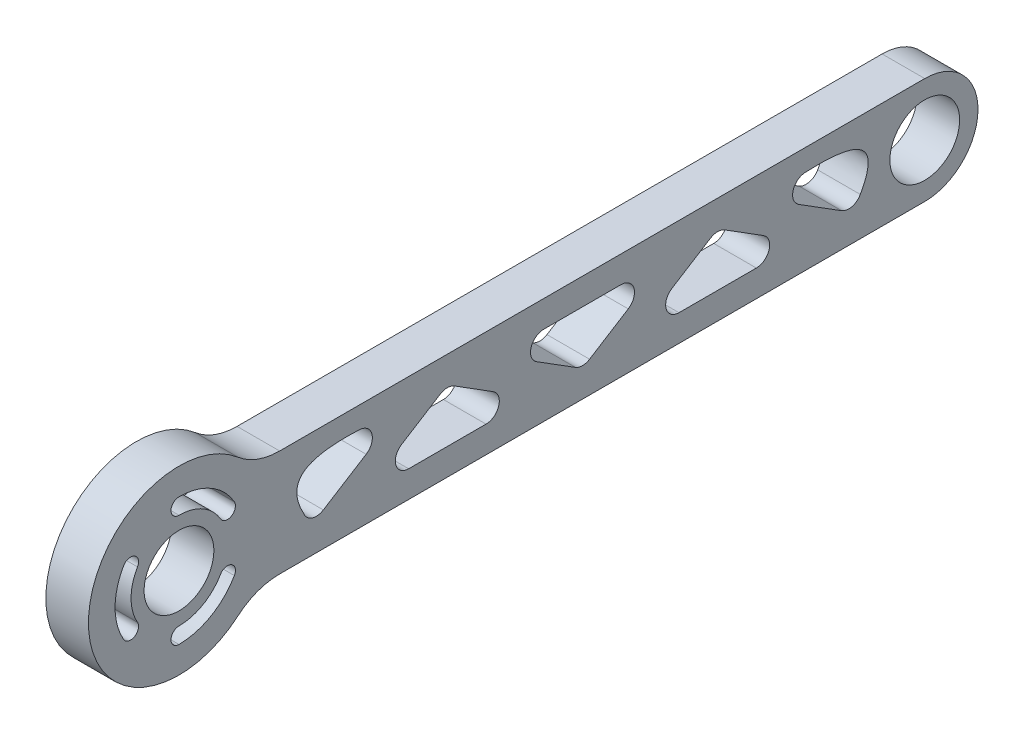
from build123d import *

# Parameters (mm, degrees)
SKETCH_1_R      = 6.55
EXTRUDE_1_DEPTH = 8


with BuildPart() as part:
    # 草图1 → 凸台-拉伸1 (new body)
    with BuildSketch(Plane(origin=(-4, 0, 0), x_dir=(0, -1, 0), z_dir=(-1, 0, 0))):
        with BuildLine():
            Line((-10, -18.894443628), (-10, -140))
            ThreePointArc((-10, -140), (0, -150), (10, -140))
            Line((10, -140), (10, -18.894443628))
            ThreePointArc((10, -18.894443628), (10.74741409, -14.725593625), (12.896551724, -11.076053161))
            ThreePointArc((12.896551724, -11.076053161), (0, 17), (-12.896551724, -11.076053161))
            ThreePointArc((-12.896551724, -11.076053161), (-10.74741409, -14.725593625), (-10, -18.894443628))
        make_face()
        with Locations((0, -140)):
            Circle(SKETCH_1_R, mode=Mode.SUBTRACT)
        Circle(SKETCH_1_R, mode=Mode.SUBTRACT)
        with BuildLine():
            Line((-4.168179012, -99.797532142), (0.381550311, -92.536811957))
            ThreePointArc((0.381550311, -92.536811957), (3.190606899, -91.461560083), (5, -93.864279815))
            Line((5, -93.864279815), (5, -108.385720185))
            ThreePointArc((5, -108.385720185), (3.190606899, -110.788439917), (0.381550311, -109.713188043))
            Line((0.381550311, -109.713188043), (-4.168179012, -102.452467858))
            ThreePointArc((-4.168179012, -102.452467858), (-4.549729323, -101.125), (-4.168179012, -99.797532142))
        make_face(mode=Mode.SUBTRACT)
        with BuildLine():
            Line((-1.347932676, -116.369603301), (3.683273316, -124.398691695))
            ThreePointArc((3.683273316, -124.398691695), (3.98786354, -126.341689874), (2.792876182, -127.903746961))
            add(Edge.make_bspline(
                [(2.792876182, -127.903746961), (-2.877603269, -131.101619406), (-5.985402229, -127.808170374), (-6.076762251, -119.793304589), (-5.963124704, -117.569487096)],
                knots=[0.005408839, 0.005408839, 0.005408839, 0.005408839, 0.693539789, 0.980498212, 0.980498212, 0.980498212, 0.980498212], degree=3))
            ThreePointArc((-5.963124704, -117.569487096), (-4.09543452, -115.277506448), (-1.347932676, -116.369603301))
        make_face(mode=Mode.SUBTRACT)
        with BuildLine():
            Line((0.381550311, -58.963188043), (-4.168179012, -51.702467858))
            ThreePointArc((-4.168179012, -51.702467858), (-4.549729323, -50.375), (-4.168179012, -49.047532142))
            Line((-4.168179012, -49.047532142), (0.381550311, -41.786811957))
            ThreePointArc((0.381550311, -41.786811957), (3.190606899, -40.711560083), (5, -43.114279815))
            Line((5, -43.114279815), (5, -57.635720185))
            ThreePointArc((5, -57.635720185), (3.190606899, -60.038439917), (0.381550311, -58.963188043))
        make_face(mode=Mode.SUBTRACT)
        with BuildLine():
            Line((3.683273317, -27.101308304), (-1.347932676, -35.130396699))
            ThreePointArc((-1.347932676, -35.130396699), (-4.095434519, -36.222493552), (-5.963124704, -33.930512906))
            add(Edge.make_bspline(
                [(-5.963124704, -33.930512906), (-6.076762251, -31.706695412), (-5.98540223, -23.691829624), (-2.877603269, -20.398380591), (2.792876182, -23.596253037)],
                knots=[0.005408839, 0.005408839, 0.005408839, 0.005408839, 0.292367263, 0.980498213, 0.980498213, 0.980498213, 0.980498213], degree=3))
            ThreePointArc((2.792876182, -23.596253037), (3.987863541, -25.158310124), (3.683273317, -27.101308304))
        make_face(mode=Mode.SUBTRACT)
        with BuildLine():
            Line((4.168179012, -77.077467858), (-0.381550311, -84.338188043))
            ThreePointArc((-0.381550311, -84.338188043), (-3.190606899, -85.413439917), (-5, -83.010720185))
            Line((-5, -83.010720185), (-5, -68.489279815))
            ThreePointArc((-5, -68.489279815), (-3.190606899, -66.086560083), (-0.381550311, -67.161811957))
            Line((-0.381550311, -67.161811957), (4.168179012, -74.422532142))
            ThreePointArc((4.168179012, -74.422532142), (4.549729323, -75.75), (4.168179012, -77.077467858))
        make_face(mode=Mode.SUBTRACT)
        with BuildLine():
            ThreePointArc((-4.5, 7.794228634), (-6.549038106, 8.34326674), (-6, 10.392304845))
            ThreePointArc((-6, 10.392304845), (0, 12), (6, 10.392304845))
            ThreePointArc((6, 10.392304845), (6.549038106, 8.34326674), (4.5, 7.794228634))
            ThreePointArc((4.5, 7.794228634), (0, 9), (-4.5, 7.794228634))
        make_face(mode=Mode.SUBTRACT)
        with BuildLine():
            ThreePointArc((9, 0), (10.5, 1.5), (12, 0))
            ThreePointArc((12, 0), (10.392304845, -6), (6, -10.392304845))
            ThreePointArc((6, -10.392304845), (3.950961894, -9.84326674), (4.5, -7.794228634))
            ThreePointArc((4.5, -7.794228634), (7.794228634, -4.5), (9, 0))
        make_face(mode=Mode.SUBTRACT)
        with BuildLine():
            ThreePointArc((-4.5, -7.794228634), (-3.950961894, -9.84326674), (-6, -10.392304845))
            ThreePointArc((-6, -10.392304845), (-10.392304845, -6), (-12, 0))
            ThreePointArc((-12, 0), (-10.5, 1.5), (-9, 0))
            ThreePointArc((-9, 0), (-7.794228634, -4.5), (-4.5, -7.794228634))
        make_face(mode=Mode.SUBTRACT)
    extrude(amount=-EXTRUDE_1_DEPTH)


solid = part.part
